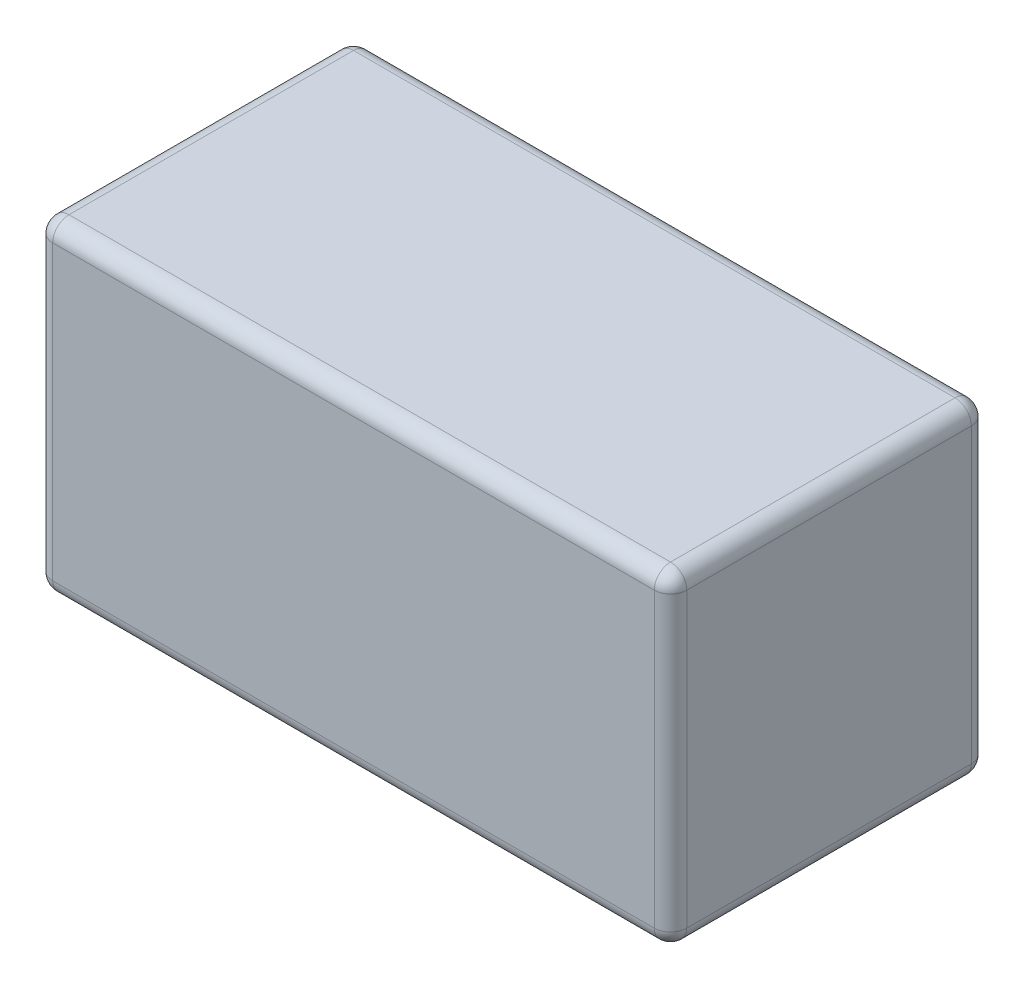
from build123d import *

# Parameters (mm, degrees)
SKETCH1_W           = 78
SKETCH1_H           = 39
BOSS_EXTRUDE1_DEPTH = 40
FILLET1_R           = 2


with BuildPart() as part:
    # Sketch1 → Boss-Extrude1 (new body)
    with BuildSketch(Plane(origin=(0, 0, 0), x_dir=(1, 0, 0), z_dir=(0, 1, 0))):
        Rectangle(SKETCH1_W, SKETCH1_H)
    extrude(amount=BOSS_EXTRUDE1_DEPTH)

    # Fillet1
    fillet1_edges = [part.edges().sort_by_distance(p)[0] for p in [
        (-39, 40, 0),
        (0, 40, 19.5),
        (39, 40, 0),
        (0, 0, 19.5),
        (-39, 0, 0),
        (0, 0, -19.5),
        (39, 0, 0),
        (39, 20, 19.5),
        (-39, 20, 19.5),
        (-39, 20, -19.5),
        (39, 20, -19.5),
        (0, 40, -19.5),
    ]]
    fillet(fillet1_edges, radius=FILLET1_R)


solid = part.part
